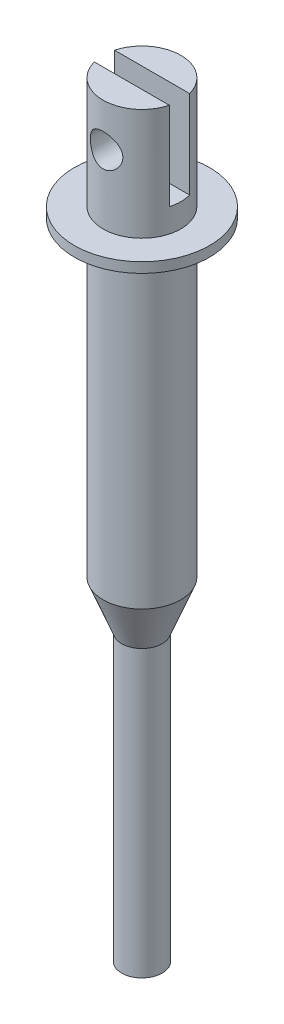
from build123d import *

# Parameters (mm, degrees)
SKETCH2_R               = 1.2
CUT_EXTRUDE1_DEPTH      = 3.875
CUT_EXTRUDE1_DEPTH_BACK = 3.875
SKETCH3_W               = 5.75
SKETCH3_H               = 1.5
CUT_EXTRUDE2_DEPTH      = 6.5
SKETCH4_R               = 5
BOSS_EXTRUDE1_DEPTH     = 0.75


with BuildPart() as part:
    # Sketch1 → Revolve1 (revolve)
    with BuildSketch(Plane.XY):
        Polygon((0, 0), (1.5, 0), (1.5, 21.1), (2.875, 24.6), (2.875, 56.6), (0, 56.6), align=None)
    revolve(axis=Axis((0, 56.6, 0), (0, -1, 0)))

    # Sketch2 → Cut-Extrude1 (cut, two sides)
    with BuildSketch(Plane.XY) as cut_extrude1_sk:
        with Locations((0, 53.4)):
            Circle(SKETCH2_R)
    extrude(amount=CUT_EXTRUDE1_DEPTH, mode=Mode.SUBTRACT)
    extrude(cut_extrude1_sk.sketch, amount=-CUT_EXTRUDE1_DEPTH_BACK, mode=Mode.SUBTRACT)

    # Sketch3 → Cut-Extrude2 (cut)
    with BuildSketch(Plane(origin=(0, 56.6, 0), x_dir=(1, 0, 0), z_dir=(0, 1, 0))):
        Rectangle(SKETCH3_W, SKETCH3_H)
    extrude(amount=-CUT_EXTRUDE2_DEPTH, mode=Mode.SUBTRACT)

    # Sketch4 → Boss-Extrude1 (add)
    with BuildSketch(Plane(origin=(0, 47.6, 0), x_dir=(1, 0, 0), z_dir=(0, 1, 0))):
        Circle(SKETCH4_R)
    extrude(amount=BOSS_EXTRUDE1_DEPTH)


solid = part.part
